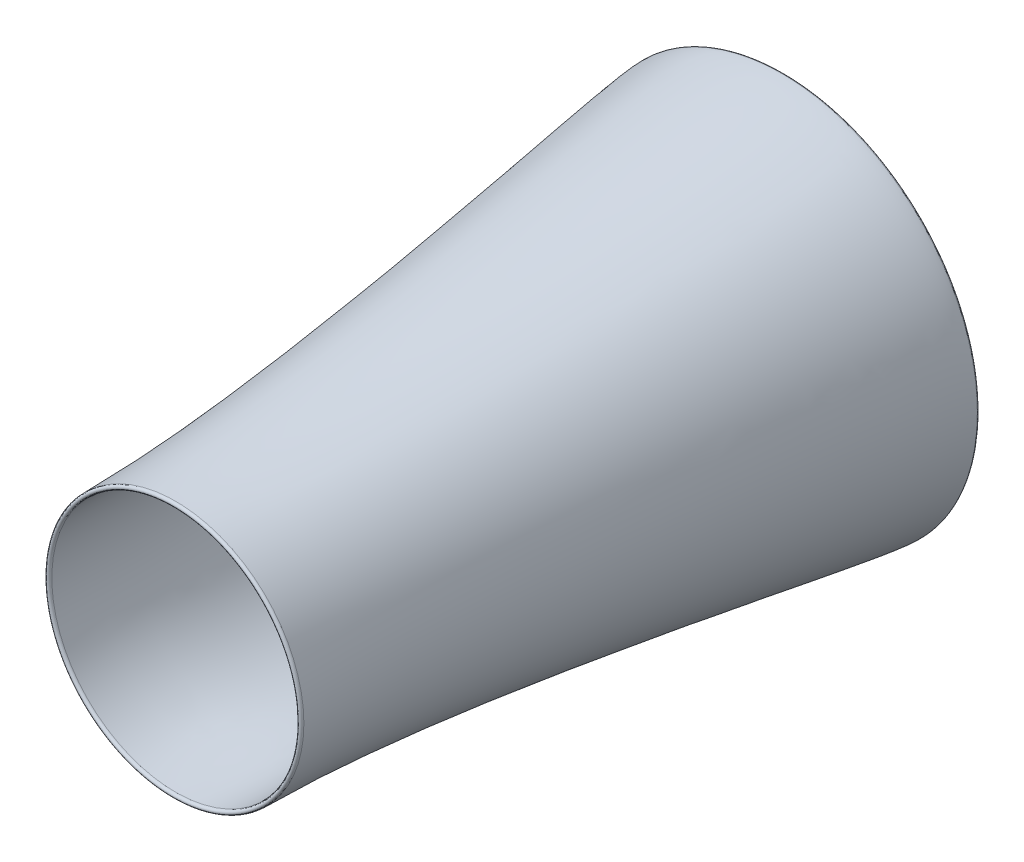
from build123d import *


with BuildPart() as part:
    # Sketch21 → Revolve2 (revolve)
    with BuildSketch(Plane(origin=(0, 0, 0), x_dir=(1, 0, 0), z_dir=(0, 1, 0))):
        with BuildLine():
            Line((-434.402318258, -2147.304598872), (-450.143329298, -2147.304598872))
            add(Edge.make_bspline(
                [(-686.282291631, -20.097532665), (-686.282291631, -145.481485041), (-450.143329298, -1416.995478487), (-450.143329298, -2147.304598872)],
                knots=[0, 0, 0, 0, 1, 1, 1, 1], degree=3))
            Line((-686.282291631, -20.097532665), (-603.463057221, -20.097532665))
            add(Edge.make_bspline(
                [(-603.463057221, -20.097532665), (-603.463057221, -72.733285187), (-549.077001449, -603.012289083), (-515.755671061, -762.888183201), (-399.895973283, -1827.467085184), (-434.402318258, -1858.195978232), (-434.402318258, -2147.304598872)],
                knots=[0, 0, 0, 0, 0.158009172, 0.206506907, 0.484977351, 1, 1, 1, 1], degree=3))
        make_face()
    revolve(axis=Axis((0, 0, 99.684784321), (0, 0, -1)))


with BuildPart() as body_2:
    # Sketch22 → Revolve3 (revolve)
    with BuildSketch(Plane(origin=(0, 0, 0), x_dir=(1, 0, 0), z_dir=(0, 1, 0))):
        with BuildLine():
            Line((-686.282291631, -20.097532665), (-603.463057221, -20.097532665))
            add(Edge.make_bspline(
                [(-686.282291631, -20.097532665), (-686.282291631, -3.164199331), (-603.463057221, -3.164199331), (-603.463057221, -20.097532665)],
                knots=[0, 0, 0, 0, 1, 1, 1, 1], degree=3))
        make_face()
    revolve(axis=Axis((0, 0, 99.684784321), (0, 0, -1)))


with BuildPart() as body_3:
    # Sketch23 → Revolve4 (revolve)
    with BuildSketch(Plane(origin=(0, 0, 0), x_dir=(1, 0, 0), z_dir=(0, 1, 0))):
        with BuildLine():
            Line((-450.143329298, -2147.304598872), (-434.402318258, -2147.304598872))
            add(Edge.make_bspline(
                [(-450.143329298, -2147.304598872), (-450.143329298, -2160.004598872), (-434.402318258, -2160.004598872), (-434.402318258, -2147.304598872)],
                knots=[0, 0, 0, 0, 1, 1, 1, 1], degree=3))
        make_face()
    revolve(axis=Axis((0, 0, 1104.756830123), (0, 0, -1)))


solid = Compound([part.part, body_2.part, body_3.part])
